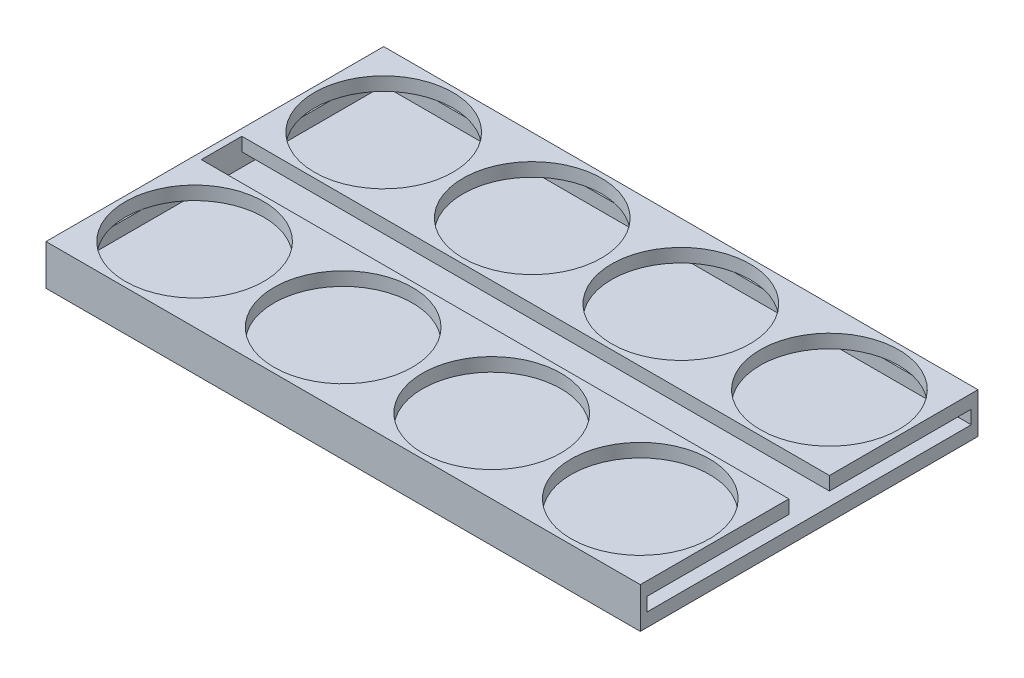
from build123d import *

# Parameters (mm, degrees)
SKETCH1_W           = 88
SKETCH1_H           = 50
BOSS_EXTRUDE1_DEPTH = 6
SKETCH2_W           = 48
SKETCH2_H           = 2
CUT_EXTRUDE1_DEPTH  = 87
SKETCH3_R           = 10.25
CUT_EXTRUDE2_DEPTH  = 2
LPATTERN1_COUNT     = 4
LPATTERN1_PITCH     = 22
SKETCH4_R           = 10.25
CUT_EXTRUDE3_DEPTH  = 2
LPATTERN2_COUNT     = 4
LPATTERN2_PITCH     = 22
SKETCH5_W           = 87
SKETCH5_H           = 6
CUT_EXTRUDE4_DEPTH  = 2


with BuildPart() as part:
    # Sketch1 → Boss-Extrude1 (new body)
    with BuildSketch(Plane(origin=(0, 0, 0), x_dir=(1, 0, 0), z_dir=(0, 1, 0))):
        with Locations((44, 25)):
            Rectangle(SKETCH1_W, SKETCH1_H)
    extrude(amount=-BOSS_EXTRUDE1_DEPTH)

    # Sketch2 → Cut-Extrude1 (cut)
    with BuildSketch(Plane(origin=(88, 0, 0), x_dir=(0, 0, -1), z_dir=(1, 0, 0))):
        with Locations((25, -3)):
            Rectangle(SKETCH2_W, SKETCH2_H)
    extrude(amount=-CUT_EXTRUDE1_DEPTH, mode=Mode.SUBTRACT)

    # Sketch3 → Cut-Extrude2 (cut)
    with BuildSketch(Plane(origin=(0, 0, 0), x_dir=(1, 0, 0), z_dir=(0, 1, 0))):
        with Locations((77, 11)):
            Circle(SKETCH3_R)
    cut_extrude2 = extrude(amount=-CUT_EXTRUDE2_DEPTH, mode=Mode.SUBTRACT)

    # LPattern1: Cut-Extrude2 ×4
    with Locations(*[(-i * LPATTERN1_PITCH, 0, 0) for i in range(1, LPATTERN1_COUNT)]):
        add(cut_extrude2, mode=Mode.SUBTRACT)

    # Sketch4 → Cut-Extrude3 (cut)
    with BuildSketch(Plane(origin=(0, 0, 0), x_dir=(1, 0, 0), z_dir=(0, 1, 0))):
        with Locations((77, 39)):
            Circle(SKETCH4_R)
    cut_extrude3 = extrude(amount=-CUT_EXTRUDE3_DEPTH, mode=Mode.SUBTRACT)

    # LPattern2: Cut-Extrude3 ×4
    with Locations(*[(-i * LPATTERN2_PITCH, 0, 0) for i in range(1, LPATTERN2_COUNT)]):
        add(cut_extrude3, mode=Mode.SUBTRACT)

    # Sketch5 → Cut-Extrude4 (cut)
    with BuildSketch(Plane(origin=(0, 0, 0), x_dir=(1, 0, 0), z_dir=(0, 1, 0))):
        with Locations((44.5, 25)):
            Rectangle(SKETCH5_W, SKETCH5_H)
    extrude(amount=-CUT_EXTRUDE4_DEPTH, mode=Mode.SUBTRACT)


solid = part.part
